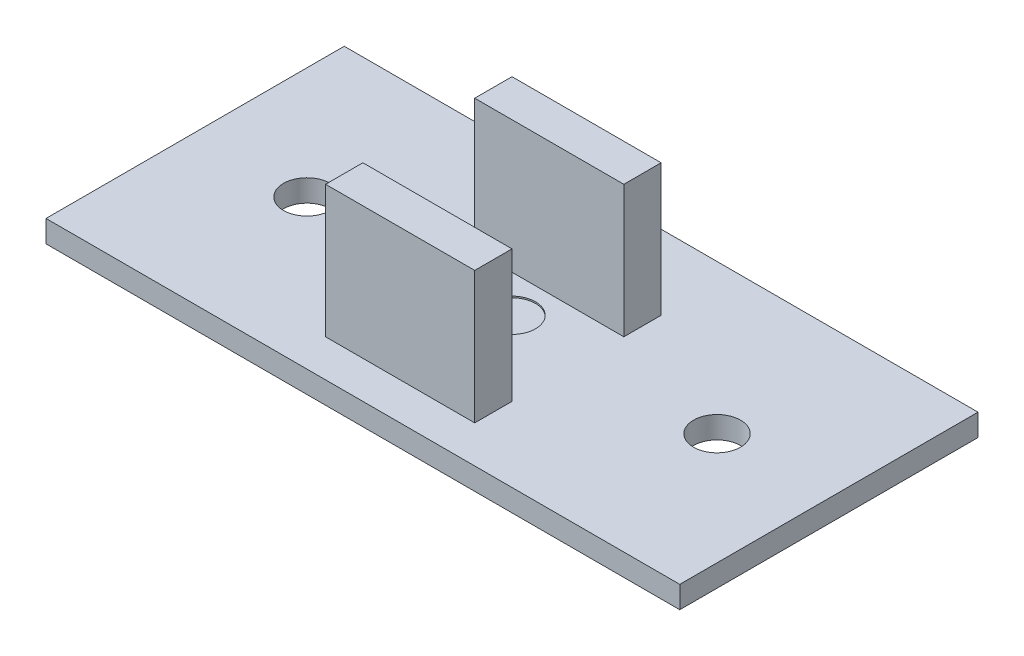
from build123d import *

# Parameters (mm, degrees)
SKETCH1_W             = 43.18
SKETCH1_H             = 20.32
SKETCH1_R             = 1.6
BOSS_EXTRUDE1_DEPTH   = 1.5
SKETCH2_W             = 10.16
SKETCH2_H             = 2.54
BOSS_EXTRUDE2_DEPTH   = 9
BOSS_EXTRUDE2_2_DEPTH = 9
SKETCH5_R             = 1.6
CUT_EXTRUDE1_DEPTH    = 0.1


with BuildPart() as part:
    # Sketch1 → Boss-Extrude1 (new body)
    with BuildSketch(Plane(origin=(0, 0, 0), x_dir=(1, 0, 0), z_dir=(0, 1, 0))):
        with Locations((21.59, 10.16)):
            Rectangle(SKETCH1_W, SKETCH1_H)
        with Locations((7.62, 10.16)):
            Circle(SKETCH1_R, mode=Mode.SUBTRACT)
        with Locations((35.56, 10.16)):
            Circle(SKETCH1_R, mode=Mode.SUBTRACT)
    extrude(amount=BOSS_EXTRUDE1_DEPTH)

    # Sketch5 → Cut-Extrude1 (cut)
    with BuildSketch(Plane(origin=(0, 1.5, 0), x_dir=(1, 0, 0), z_dir=(0, 1, 0))):
        with Locations((21.59, 10.16)):
            Circle(SKETCH5_R)
    extrude(amount=-CUT_EXTRUDE1_DEPTH, mode=Mode.SUBTRACT)


with BuildPart() as body_2:
    # Sketch2 → Boss-Extrude2 (new body)
    with BuildSketch(Plane(origin=(0, 1.5, 0), x_dir=(1, 0, 0), z_dir=(0, 1, 0))):
        with Locations((21.59, 3.81)):
            Rectangle(SKETCH2_W, SKETCH2_H)
    extrude(amount=BOSS_EXTRUDE2_DEPTH)


with BuildPart() as body_3:
    # Sketch2 → Boss-Extrude2 2 (new body)
    with BuildSketch(Plane(origin=(0, 1.5, 0), x_dir=(1, 0, 0), z_dir=(0, 1, 0))):
        with Locations((21.59, 13.97)):
            Rectangle(SKETCH2_W, SKETCH2_H)
    extrude(amount=BOSS_EXTRUDE2_2_DEPTH)


solid = Compound([part.part, body_2.part, body_3.part])
